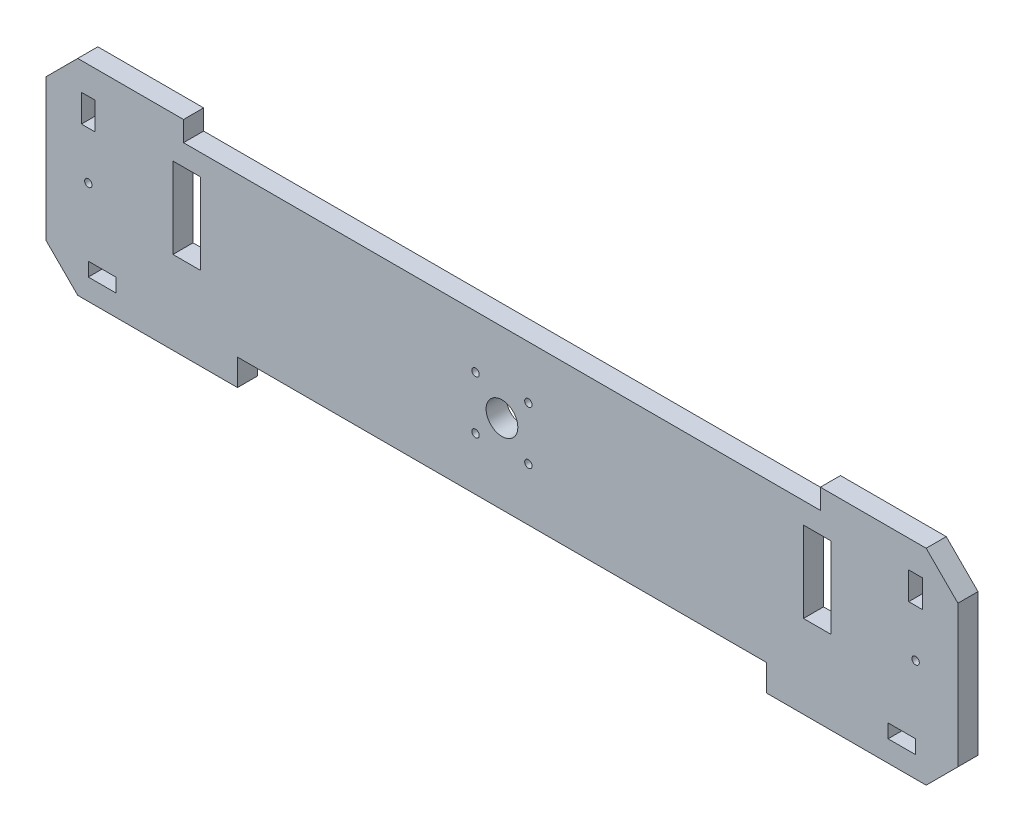
from build123d import *

# Parameters (mm, degrees)
CROQUIS1_R              = 3.5
CROQUIS1_R_2            = 15
CROQUIS1_W              = 26
CROQUIS1_H              = 76.5
CROQUIS1_H_2            = 13
CROQUIS1_W_2            = 13
CROQUIS1_H_3            = 26
SALIENTE_EXTRUIR1_DEPTH = 19


with BuildPart() as part:
    # Croquis1 → Saliente-Extruir1 (new body)
    with BuildSketch(Plane.XY):
        Polygon((-301, 194), (-301, 175), (301, 175), (301, 194), (401, 194), (431, 164), (431, 30), (401, 0), (250, 0), (250, 25), (-250, 25), (-250, 0), (-401, 0), (-431, 30), (-431, 164), (-401, 194), align=None)
        with Locations((-391, 97)):
            Circle(CROQUIS1_R, mode=Mode.SUBTRACT)
        with Locations((391, 97)):
            Circle(CROQUIS1_R, mode=Mode.SUBTRACT)
        with Locations((0, 100)):
            Circle(CROQUIS1_R_2, mode=Mode.SUBTRACT)
        with Locations((-25, 125)):
            Circle(CROQUIS1_R, mode=Mode.SUBTRACT)
        with Locations((25, 125)):
            Circle(CROQUIS1_R, mode=Mode.SUBTRACT)
        with Locations((25, 75)):
            Circle(CROQUIS1_R, mode=Mode.SUBTRACT)
        with Locations((-25, 75)):
            Circle(CROQUIS1_R, mode=Mode.SUBTRACT)
        with Locations((-298, 116.75)):
            Rectangle(CROQUIS1_W, CROQUIS1_H, mode=Mode.SUBTRACT)
        with Locations((298, 116.75)):
            Rectangle(CROQUIS1_W, CROQUIS1_H, mode=Mode.SUBTRACT)
        with Locations((378, 26.5)):
            Rectangle(CROQUIS1_W, CROQUIS1_H_2, mode=Mode.SUBTRACT)
        with Locations((-378, 26.5)):
            Rectangle(CROQUIS1_W, CROQUIS1_H_2, mode=Mode.SUBTRACT)
        with Locations((391, 155)):
            Rectangle(CROQUIS1_W_2, CROQUIS1_H_3, mode=Mode.SUBTRACT)
        with Locations((-391, 155)):
            Rectangle(CROQUIS1_W_2, CROQUIS1_H_3, mode=Mode.SUBTRACT)
    extrude(amount=SALIENTE_EXTRUIR1_DEPTH)


solid = part.part
